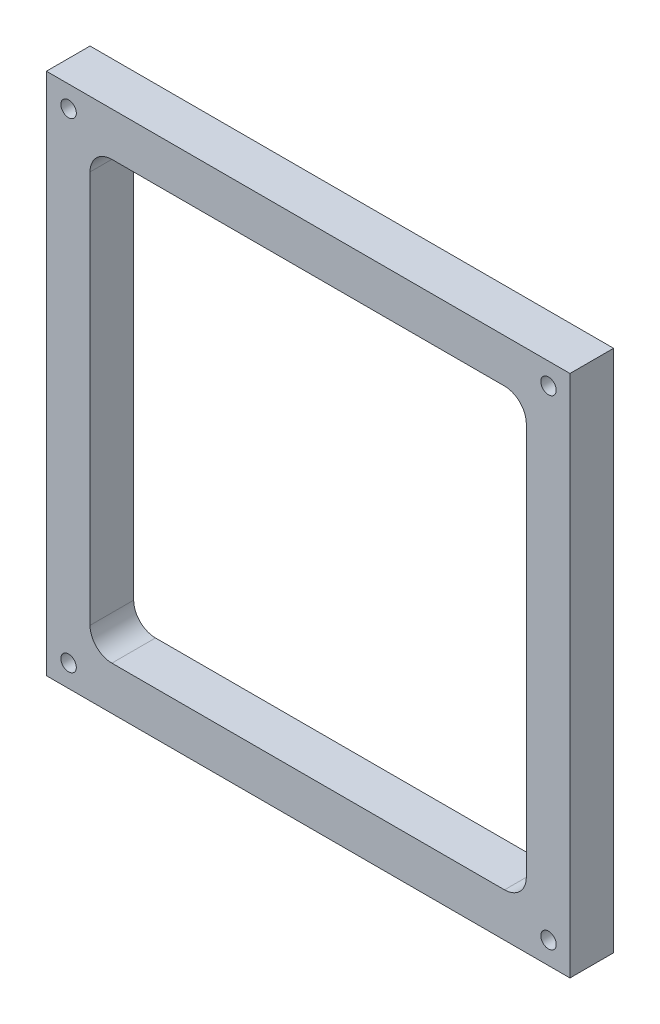
from build123d import *

# Parameters (mm, degrees)
SKETCH1_W             = 152.4
SKETCH1_H             = 152.4
BOSS_EXTRUDE1_DEPTH   = 12.7
F_8_CLEARANCE_HOLE2_D = 4.4958
LPATTERN1_COUNT       = 2
LPATTERN1_PITCH       = 139.7
LPATTERN1_COUNT_DIR2  = 2
LPATTERN1_PITCH_DIR2  = 139.7


with BuildPart() as part:
    # Sketch1 → Boss-Extrude1 (new body)
    with BuildSketch(Plane.XY):
        with Locations((15.057340396, 3.848381836)):
            Rectangle(SKETCH1_W, SKETCH1_H)
        with BuildLine():
            Line((-42.092659604, 67.348381836), (72.207340396, 67.348381836))
            ThreePointArc((72.207340396, 67.348381836), (76.697468456, 65.488509896), (78.557340396, 60.998381836))
            Line((78.557340396, 60.998381836), (78.557340396, -53.301618164))
            ThreePointArc((78.557340396, -53.301618164), (76.697468456, -57.791746225), (72.207340396, -59.651618164))
            Line((72.207340396, -59.651618164), (-42.092659604, -59.651618164))
            ThreePointArc((-42.092659604, -59.651618164), (-46.582787665, -57.791746225), (-48.442659604, -53.301618164))
            Line((-48.442659604, -53.301618164), (-48.442659604, 60.998381836))
            ThreePointArc((-48.442659604, 60.998381836), (-46.582787665, 65.488509896), (-42.092659604, 67.348381836))
        make_face(mode=Mode.SUBTRACT)
    extrude(amount=BOSS_EXTRUDE1_DEPTH)

    # #8 Clearance Hole2 (through all)
    with Locations(Plane.XY.offset(12.7)):
        with Locations((-54.687907486, 73.795789856)):
            f_8_clearance_hole2 = Hole(F_8_CLEARANCE_HOLE2_D / 2)

    # LPattern1: 8 Clearance Hole2 2 × 2
    with Locations(*[(i * LPATTERN1_PITCH, -j * LPATTERN1_PITCH_DIR2, 0) for i in range(LPATTERN1_COUNT) for j in range(LPATTERN1_COUNT_DIR2) if (i, j) != (0, 0)]):
        add(f_8_clearance_hole2, mode=Mode.SUBTRACT)


solid = part.part
